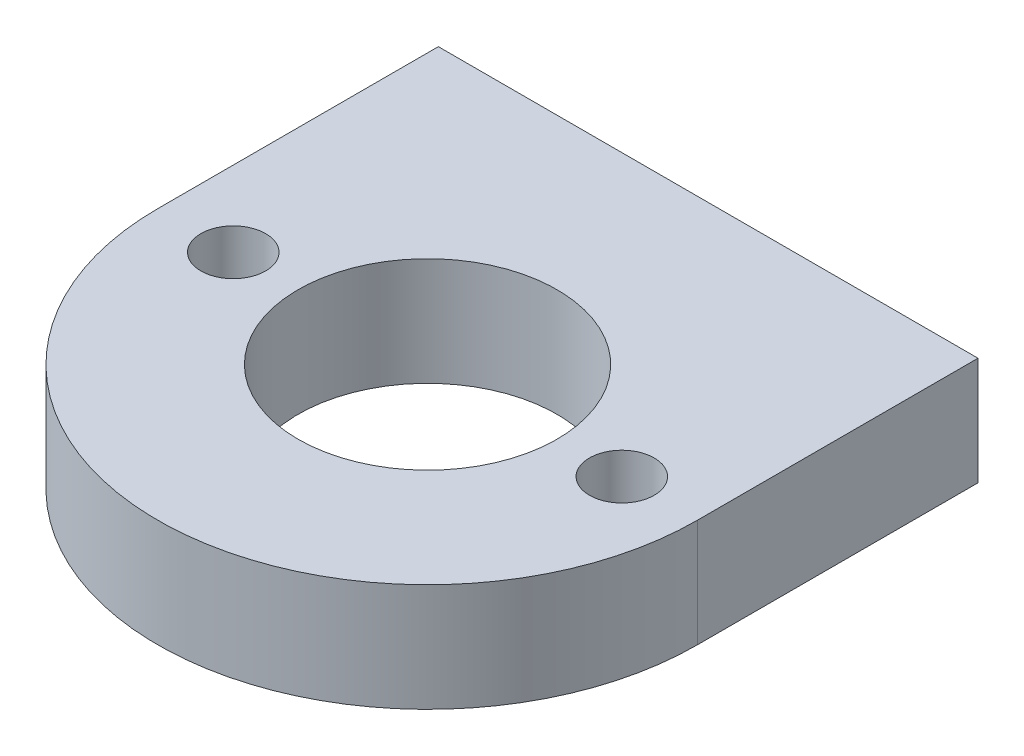
from build123d import *

# Parameters (mm, degrees)
SKETCH_1_W          = 25
SKETCH_1_H          = 5
EXTRUDE_1_DEPTH     = 13
SKETCH_2_R          = 12.5
EXTRUDE_2_DEPTH     = 5
CUT_EXTRUDE_1_DEPTH = 5
SKETCH_4_R          = 1.5
CUT_EXTRUDE_2_DEPTH = 5
M3X0_5_1_D          = 2.5
M3X0_5_1_DEPTH      = 10
M3X0_5_1_TIP        = 0.751075774


with BuildPart() as part:
    # ｽｹｯﾁ1 → ﾎﾞｽ - 押し出し1 (new body)
    with BuildSketch(Plane.XY):
        Rectangle(SKETCH_1_W, SKETCH_1_H)
    extrude(amount=EXTRUDE_1_DEPTH)

    # ｽｹｯﾁ2 → ﾎﾞｽ - 押し出し2 (add)
    with BuildSketch(Plane.XZ.offset(2.5)):
        with Locations((0, 13)):
            Circle(SKETCH_2_R)
    extrude(amount=-EXTRUDE_2_DEPTH)

    # ｽｹｯﾁ3 → ｶｯﾄ - 押し出し1 (cut)
    with BuildSketch(Plane(origin=(0, 2.5, 0), x_dir=(1, 0, 0), z_dir=(0, 1, 0))):
        with BuildLine():
            ThreePointArc((-6, -13), (0, -19), (6, -13))
            Line((6, -13), (-6, -13))
        make_face()
        with BuildLine():
            Line((-6, -13), (6, -13))
            ThreePointArc((6, -13), (0, -7), (-6, -13))
        make_face()
    extrude(amount=-CUT_EXTRUDE_1_DEPTH, mode=Mode.SUBTRACT)

    # ｽｹｯﾁ4 → ｶｯﾄ - 押し出し2 (cut)
    with BuildSketch(Plane(origin=(0, 2.5, 0), x_dir=(1, 0, 0), z_dir=(0, 1, 0))):
        with Locations(Location((9, -13, 0), (0, 0, 270))):  # turned: the seam where the file's is
            Circle(SKETCH_4_R)
        with Locations(Location((-9, -13, 0), (0, 0, 270))):  # turned: the seam where the file's is
            Circle(SKETCH_4_R)
    extrude(amount=-CUT_EXTRUDE_2_DEPTH, mode=Mode.SUBTRACT)

    # M3x0.5 ねじ穴1
    with Locations(Plane(origin=(0, 0, 0), x_dir=(-1, 0, 0), z_dir=(0, 0, -1))):
        with Locations((-9, 0), (9, 0)):
            Hole(M3X0_5_1_D / 2, depth=M3X0_5_1_DEPTH)
            with Locations((0, 0, -(M3X0_5_1_DEPTH + M3X0_5_1_TIP / 2))):  # 118° drill point
                Cone(0, M3X0_5_1_D / 2, M3X0_5_1_TIP, mode=Mode.SUBTRACT)


solid = part.part
